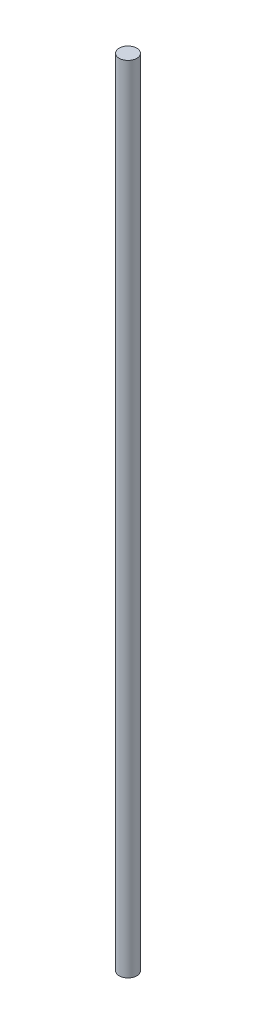
from build123d import *

# Parameters (mm, degrees)
SKETCH1_R           = 6.35
BOSS_EXTRUDE1_DEPTH = 571.5


with BuildPart() as part:
    # Sketch1 → Boss-Extrude1 (new body)
    with BuildSketch(Plane(origin=(0, 0, 0), x_dir=(1, 0, 0), z_dir=(0, 1, 0))):
        Circle(SKETCH1_R)
    extrude(amount=BOSS_EXTRUDE1_DEPTH)


solid = part.part
